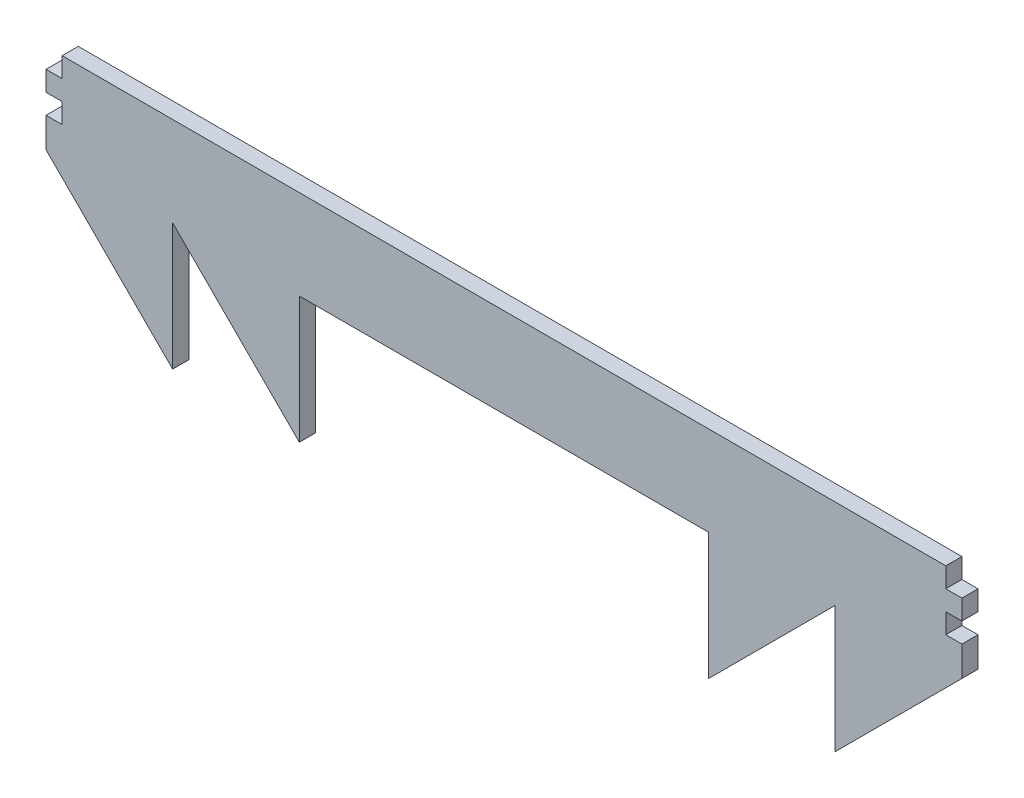
from build123d import *

# Parameters (mm, degrees)
BOSS_EXTRUDE1_DEPTH = 2.7


with BuildPart() as part:
    # Sketch1 → Boss-Extrude1 (new body)
    with BuildSketch(Plane.XY):
        Polygon((-76.7, -1.666666667), (-76.7, 1.666666667), (-74, 1.666666667), (-74, 5), (74, 5), (74, 1.666666667), (76.7, 1.666666667), (76.7, -1.666666667), (74, -1.666666667), (74, -5), (76.7, -5), (76.7, -10), (55.486796564, -31.213203436), (55.486796564, -10), (34.273593129, -31.213203436), (34.273593129, -10), (-34.273593129, -10), (-34.273593129, -31.213203436), (-55.486796564, -10), (-55.486796564, -31.213203436), (-76.7, -10), (-76.7, -5), (-74, -5), (-74, -1.666666667), align=None)
    extrude(amount=BOSS_EXTRUDE1_DEPTH)


solid = part.part
